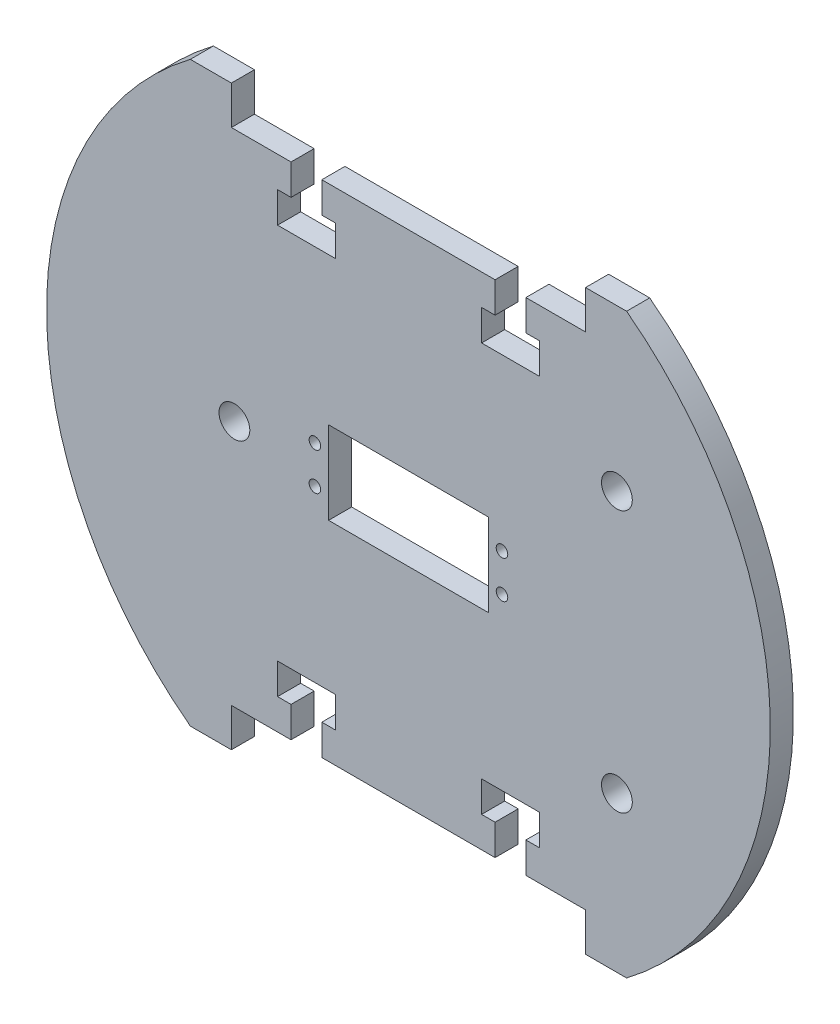
from build123d import *

# Parameters (mm, degrees)
SKETCH8_R               = 1.5
SKETCH8_W               = 41.5
SKETCH8_H               = 21.5
BOSS_EXTRUDE1_DEPTH     = 6
SKETCH10_R              = 4
CUT_EXTRUDE2_DEPTH      = 1
CUT_EXTRUDE2_DEPTH_BACK = 7


with BuildPart() as part:
    # Sketch8 → Boss-Extrude1 (new body)
    with BuildSketch(Plane.XY):
        with BuildLine():
            Line((-56.665686266, -75), (-46, -75))
            Line((-46, -75), (-46, -65))
            Line((-46, -65), (-30.5, -65))
            Line((-30.5, -65), (-30.5, -57.029309822))
            Line((-30.5, -57.029309822), (-34, -57.029309822))
            Line((-34, -57.029309822), (-34, -49.029309822))
            Line((-34, -49.029309822), (-19, -49.029309822))
            Line((-19, -49.029309822), (-19, -57.029309822))
            Line((-19, -57.029309822), (-22.5, -57.029309822))
            Line((-22.5, -57.029309822), (-22.5, -65))
            Line((-22.5, -65), (22.5, -65))
            Line((22.5, -65), (22.5, -57.029309822))
            Line((22.5, -57.029309822), (19, -57.029309822))
            Line((19, -57.029309822), (19, -49.029309822))
            Line((19, -49.029309822), (34, -49.029309822))
            Line((34, -49.029309822), (34, -57.029309822))
            Line((34, -57.029309822), (30.5, -57.029309822))
            Line((30.5, -57.029309822), (30.5, -65))
            Line((30.5, -65), (46, -65))
            Line((46, -65), (46, -75))
            Line((46, -75), (56.665686266, -75))
            ThreePointArc((56.665686266, -75), (94, 0), (56.665686266, 75))
            Line((56.665686266, 75), (46, 75))
            Line((46, 75), (46, 65))
            Line((46, 65), (30.5, 65))
            Line((30.5, 65), (30.5, 57.029309822))
            Line((30.5, 57.029309822), (34, 57.029309822))
            Line((34, 57.029309822), (34, 49.029309822))
            Line((34, 49.029309822), (19, 49.029309822))
            Line((19, 49.029309822), (19, 57.029309822))
            Line((19, 57.029309822), (22.5, 57.029309822))
            Line((22.5, 57.029309822), (22.5, 65))
            Line((22.5, 65), (-22.5, 65))
            Line((-22.5, 65), (-22.5, 57.029309822))
            Line((-22.5, 57.029309822), (-19, 57.029309822))
            Line((-19, 57.029309822), (-19, 49.029309822))
            Line((-19, 49.029309822), (-34, 49.029309822))
            Line((-34, 49.029309822), (-34, 57.029309822))
            Line((-34, 57.029309822), (-30.5, 57.029309822))
            Line((-30.5, 57.029309822), (-30.5, 65))
            Line((-30.5, 65), (-46, 65))
            Line((-46, 65), (-46, 75))
            Line((-46, 75), (-56.665686266, 75))
            ThreePointArc((-56.665686266, 75), (-94, 0), (-56.665686266, -75))
        make_face()
        with Locations((-24.3, -4.875)):
            Circle(SKETCH8_R, mode=Mode.SUBTRACT)
        with Locations((-24.3, 4.875)):
            Circle(SKETCH8_R, mode=Mode.SUBTRACT)
        with Locations((24.3, 4.875)):
            Circle(SKETCH8_R, mode=Mode.SUBTRACT)
        with Locations((24.3, -4.875)):
            Circle(SKETCH8_R, mode=Mode.SUBTRACT)
        Rectangle(SKETCH8_W, SKETCH8_H, mode=Mode.SUBTRACT)
    extrude(amount=BOSS_EXTRUDE1_DEPTH)

    # Sketch10 → Cut-Extrude2 (cut, two sides)
    with BuildSketch(Plane.XY.offset(6)) as cut_extrude2_sk:
        with Locations((54.15, -34.722964698)):
            Circle(SKETCH10_R)
        with Locations((54.15, 33.277035302)):
            Circle(SKETCH10_R)
        with Locations((-45.21, -0.722964698)):
            Circle(SKETCH10_R)
    extrude(amount=CUT_EXTRUDE2_DEPTH, mode=Mode.SUBTRACT)
    extrude(cut_extrude2_sk.sketch, amount=-CUT_EXTRUDE2_DEPTH_BACK, mode=Mode.SUBTRACT)


solid = part.part
